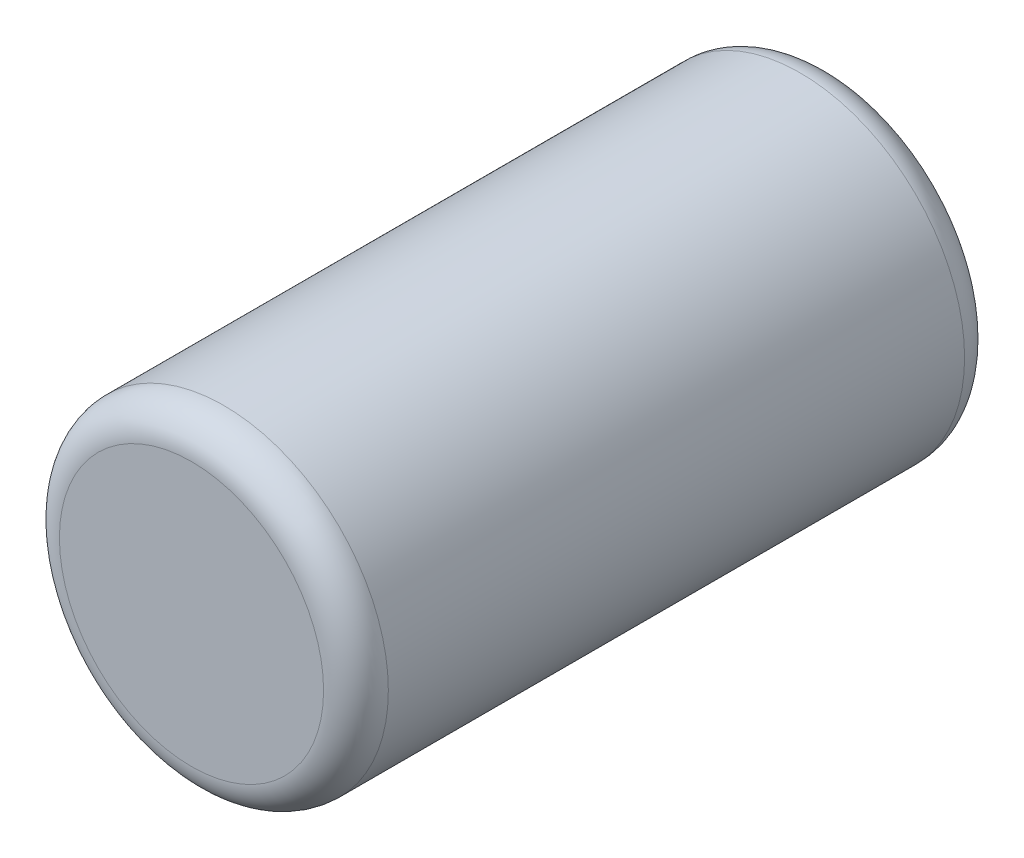
from build123d import *

# Parameters (mm, degrees)
SKETCH1_R           = 25.4
BOSS_EXTRUDE1_DEPTH = 99
FILLET1_R           = 5


with BuildPart() as part:
    # Sketch1 → Boss-Extrude1 (new body)
    with BuildSketch(Plane.XY):
        Circle(SKETCH1_R)
    extrude(amount=BOSS_EXTRUDE1_DEPTH)

    # Fillet1
    fillet1_edges = [part.edges().sort_by_distance(p)[0] for p in [
        (-25.4, 0, 0),
        (-25.4, 0, 99),
    ]]
    fillet(fillet1_edges, radius=FILLET1_R)


solid = part.part
